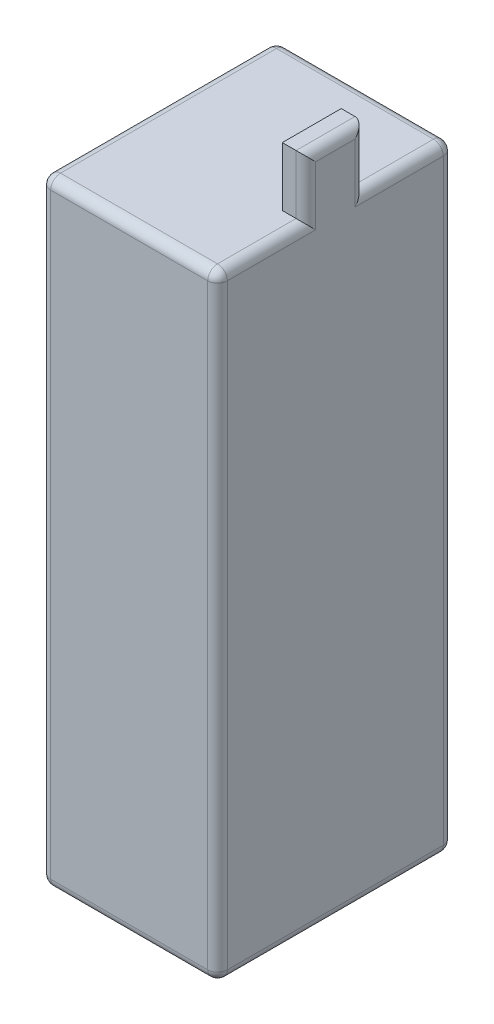
from build123d import *

# Parameters (mm, degrees)
SKETCH1_W           = 45
SKETCH1_H           = 60
BOSS_EXTRUDE1_DEPTH = 157
SKETCH2_W           = 6
SKETCH2_H           = 15
BOSS_EXTRUDE2_DEPTH = 15
FILLET1_R           = 2.5


with BuildPart() as part:
    # Sketch1 → Boss-Extrude1 (new body)
    with BuildSketch(Plane(origin=(0, 0, 0), x_dir=(1, 0, 0), z_dir=(0, 1, 0))):
        with Locations((22.5, 30)):
            Rectangle(SKETCH1_W, SKETCH1_H)
    extrude(amount=BOSS_EXTRUDE1_DEPTH)

    # Sketch2 → Boss-Extrude2 (add)
    with BuildSketch(Plane(origin=(0, 157, 0), x_dir=(1, 0, 0), z_dir=(0, 1, 0))):
        with Locations((42, 30)):
            Rectangle(SKETCH2_W, SKETCH2_H)
    extrude(amount=BOSS_EXTRUDE2_DEPTH)

    # Fillet1
    fillet1_edges = [part.edges().sort_by_distance(p)[0] for p in [
        (45, 157, -11.25),
        (45, 157, -48.75),
        (45, 164.5, -22.5),
        (45, 164.5, -37.5),
        (22.5, 157, -60),
        (45, 172, -30),
        (0, 157, -30),
        (22.5, 0, -60),
        (45, 0, -30),
        (22.5, 0, 0),
        (0, 0, -30),
        (0, 78.5, -60),
        (45, 78.5, -60),
        (45, 78.5, 0),
        (0, 78.5, 0),
        (22.5, 157, 0),
    ]]
    fillet(fillet1_edges, radius=FILLET1_R)


solid = part.part
